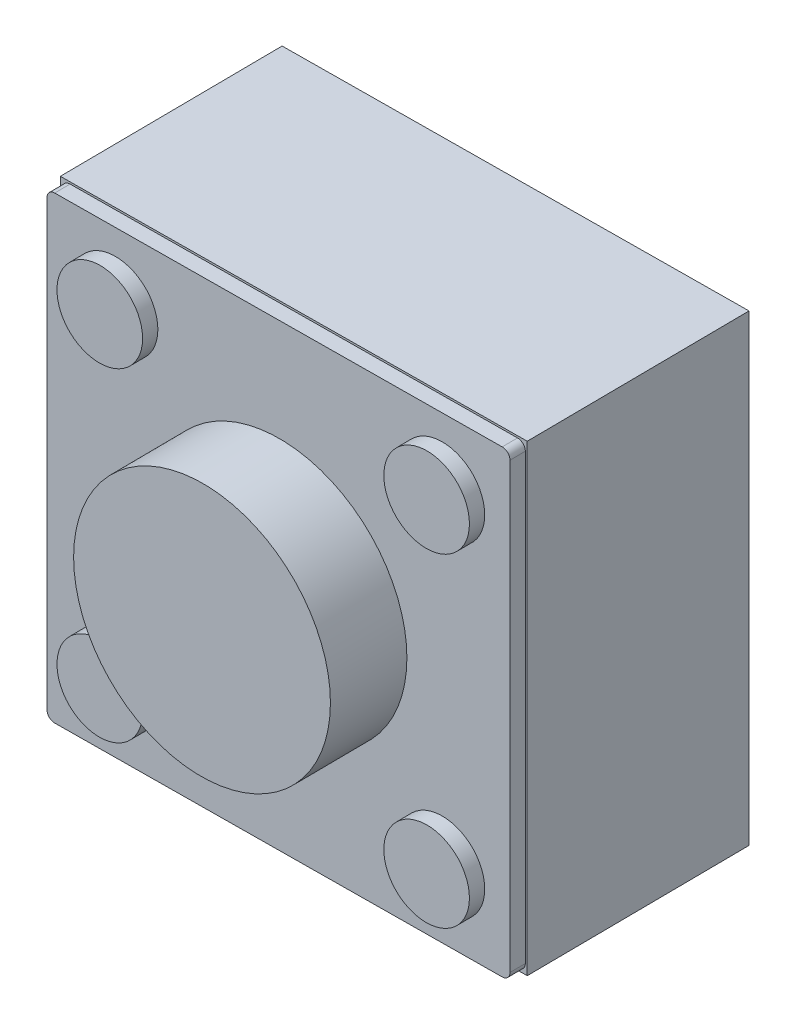
from build123d import *

# Parameters (mm, degrees)
SKETCH1_W             = 5.95
SKETCH1_H             = 5.95
BOSS_EXTRUDE1_DEPTH   = 0.1
BOSS_EXTRUDE2_START   = 0.1
SKETCH2_W             = 6
SKETCH2_H             = 6
BOSS_EXTRUDE2_DEPTH   = 2.9
FILLET1_R             = 0.1
BOSS_EXTRUDE3_START   = -0.1
SKETCH3_R             = 1.65
SKETCH3_R_2           = 0.55
BOSS_EXTRUDE3_DEPTH   = 0.2
BOSS_EXTRUDE4_START   = -0.1
SKETCH4_R             = 1.65
BOSS_EXTRUDE4_DEPTH   = 1
BODY_MOVE_COPY1_ANGLE = 179.5


with BuildPart() as part:
    # Sketch1 → Boss-Extrude1 (new body, symmetric)
    with BuildSketch(Plane.XY):
        with Locations((-2.975, -2.975)):
            Rectangle(SKETCH1_W, SKETCH1_H)
    extrude(amount=BOSS_EXTRUDE1_DEPTH, both=True)

    # Sketch2 → Boss-Extrude2 (add)
    with BuildSketch(Plane.XY.offset(BOSS_EXTRUDE2_START)):
        with Locations((-2.975, -2.975)):
            Rectangle(SKETCH2_W, SKETCH2_H)
    extrude(amount=BOSS_EXTRUDE2_DEPTH)

    # Fillet1
    fillet1_edges = [part.edges().sort_by_distance(p)[0] for p in [
        (0, -5.95, 0),
        (-5.95, -5.95, 0),
        (-5.95, 0, 0),
        (0, 0, 0),
    ]]
    fillet(fillet1_edges, radius=FILLET1_R)

    # Sketch3 → Boss-Extrude3 (add)
    with BuildSketch(Plane.XY.offset(BOSS_EXTRUDE3_START)):
        with Locations((-2.975, -2.975)):
            Circle(SKETCH3_R)
        with Locations((-5.075, -0.875)):
            Circle(SKETCH3_R_2)
        with Locations((-5.075, -5.075)):
            Circle(SKETCH3_R_2)
        with Locations((-0.875, -5.075)):
            Circle(SKETCH3_R_2)
        with Locations((-0.875, -0.875)):
            Circle(SKETCH3_R_2)
    extrude(amount=-BOSS_EXTRUDE3_DEPTH)

    # Sketch4 → Boss-Extrude4 (add)
    with BuildSketch(Plane.XY.offset(BOSS_EXTRUDE4_START)):
        with Locations((-2.975, -2.975)):
            Circle(SKETCH4_R)
    extrude(amount=-BOSS_EXTRUDE4_DEPTH)


with BuildPart() as part_1:
    # Body-Move/Copy1: moved
    add(part.part.rotate(Axis((-2.975, 0, 0.95), (0, -1, 0)), BODY_MOVE_COPY1_ANGLE))


solid = part_1.part
